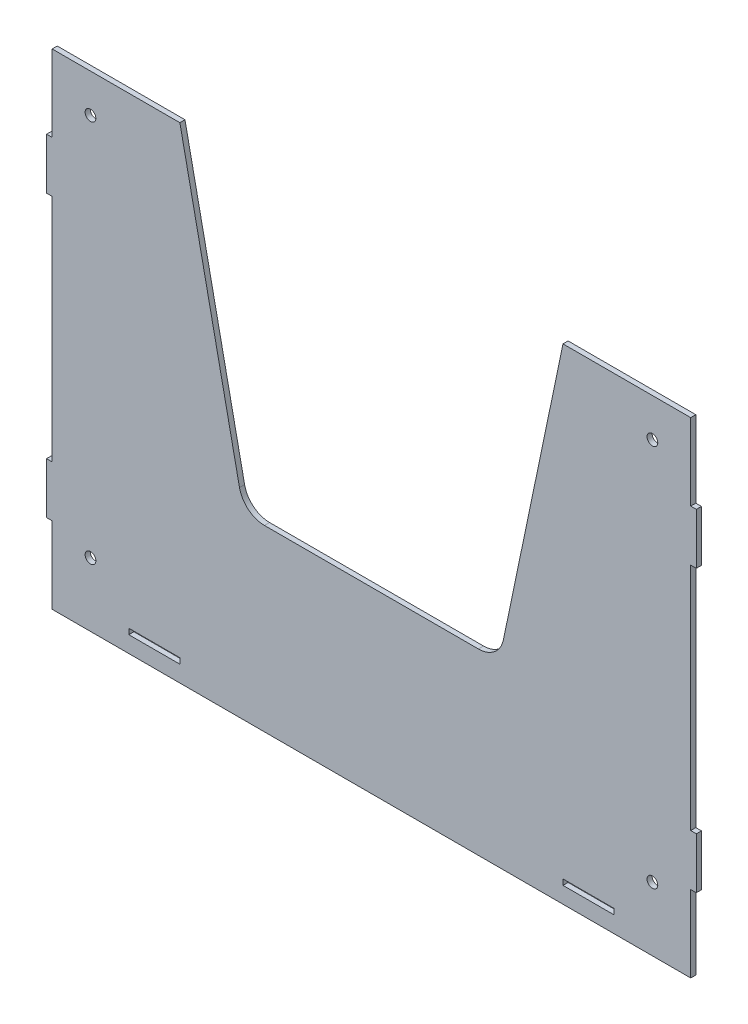
from build123d import *

# Parameters (mm, degrees)
SKETCH1_W           = 20
SKETCH1_H           = 2.2
BOSS_EXTRUDE1_DEPTH = 2
FILLET1_R           = 10
SKETCH2_R           = 2.1
CUT_EXTRUDE1_DEPTH  = 5


with BuildPart() as part:
    # Sketch1 → Boss-Extrude1 (new body)
    with BuildSketch(Plane.XY):
        Polygon((125.000000001, -10.433333333), (-124.999999999, -10.433333333), (-124.999999999, 19.566666667), (-127.199999999, 19.566666667), (-127.199999999, 39.566666667), (-124.999999999, 39.566666667), (-124.999999999, 129.566666667), (-127.199999999, 129.566666667), (-127.199999999, 149.566666667), (-124.999999999, 149.566666667), (-124.999999999, 179.566666667), (-74.999999999, 179.566666667), (-50, 59.566666667), (50, 59.566666667), (75.000000001, 179.566666667), (125.000000001, 179.566666667), (125.000000001, 149.566666667), (127.200000001, 149.566666667), (127.200000001, 129.566666667), (125.000000001, 129.566666667), (125.000000001, 39.566666667), (127.200000001, 39.566666667), (127.200000001, 19.566666667), (125.000000001, 19.566666667), align=None)
        with Locations((85.000000001, -2.933333333)):
            Rectangle(SKETCH1_W, SKETCH1_H, mode=Mode.SUBTRACT)
        with Locations((-84.999999999, -2.933333333)):
            Rectangle(SKETCH1_W, SKETCH1_H, mode=Mode.SUBTRACT)
    extrude(amount=BOSS_EXTRUDE1_DEPTH)

    # Fillet1
    fillet1_edges = [part.edges().sort_by_distance(p)[0] for p in [
        (-50, 59.566666667, 1),
        (50, 59.566666667, 1),
    ]]
    fillet(fillet1_edges, radius=FILLET1_R)

    # Sketch2 → Cut-Extrude1 (cut)
    with BuildSketch(Plane.XY.offset(2)):
        with Locations((-109.999999999, 14.566666667)):
            Circle(SKETCH2_R)
        with Locations((110.000000001, 14.566666667)):
            Circle(SKETCH2_R)
        with Locations((110.000000001, 164.566666667)):
            Circle(SKETCH2_R)
        with Locations((-109.999999999, 164.566666667)):
            Circle(SKETCH2_R)
    extrude(amount=-CUT_EXTRUDE1_DEPTH, mode=Mode.SUBTRACT)


solid = part.part
